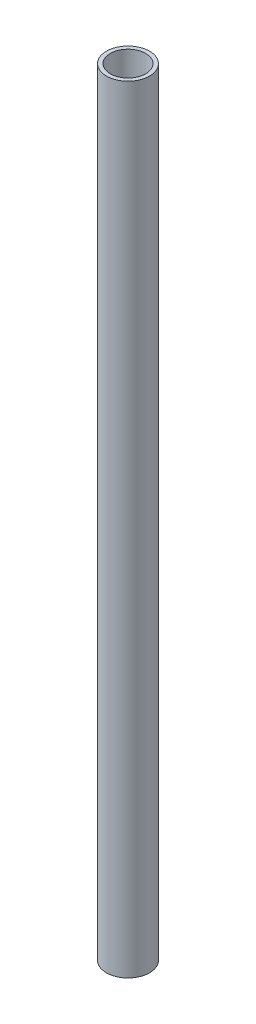
from build123d import *

# Parameters (mm, degrees)
SKETCH1_R           = 12.7
SKETCH1_R_2         = 10.414
BOSS_EXTRUDE1_DEPTH = 457.2


with BuildPart() as part:
    # Sketch1 → Boss-Extrude1 (new body)
    with BuildSketch(Plane(origin=(0, 0, 0), x_dir=(1, 0, 0), z_dir=(0, 1, 0))):
        Circle(SKETCH1_R)
        Circle(SKETCH1_R_2, mode=Mode.SUBTRACT)
    extrude(amount=BOSS_EXTRUDE1_DEPTH)


solid = part.part
